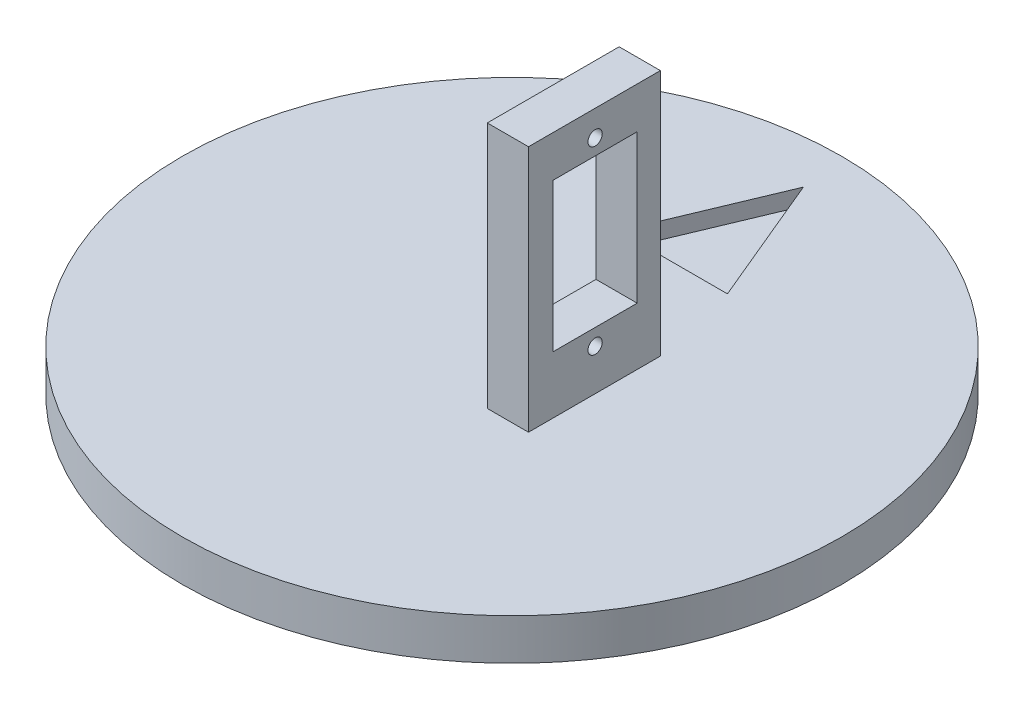
from build123d import *

# Parameters (mm, degrees)
SKETCH1_R           = 50.8
BOSS_EXTRUDE1_DEPTH = 6.35
SKETCH2_W           = 6.35
SKETCH2_H           = 20.32
BOSS_EXTRUDE2_DEPTH = 38.1
SKETCH3_R           = 1.1
SKETCH3_W           = 12.939919869
SKETCH3_H           = 22.881654632
CUT_EXTRUDE1_DEPTH  = 12.7
CUT_EXTRUDE2_DEPTH  = 2.54


with BuildPart() as part:
    # Sketch1 → Boss-Extrude1 (new body)
    with BuildSketch(Plane(origin=(0, 0, 0), x_dir=(1, 0, 0), z_dir=(0, 1, 0))):
        Circle(SKETCH1_R)
    extrude(amount=BOSS_EXTRUDE1_DEPTH)

    # Sketch2 → Boss-Extrude2 (add)
    with BuildSketch(Plane(origin=(0, 6.35, 0), x_dir=(1, 0, 0), z_dir=(0, 1, 0))):
        with Locations((9.525, 0)):
            Rectangle(SKETCH2_W, SKETCH2_H)
    extrude(amount=BOSS_EXTRUDE2_DEPTH)

    # Sketch3 → Cut-Extrude1 (cut)
    with BuildSketch(Plane(origin=(6.35, 55.246794414, 64.642959957), x_dir=(0, 0, 1), z_dir=(-1, 0, 0))):
        with Locations((-64.750269074, -14.746794414)):
            Circle(SKETCH3_R)
        with Locations((-64.750269074, -42.546794414)):
            Circle(SKETCH3_R)
        with Locations((-64.762919892, -28.608275818)):
            Rectangle(SKETCH3_W, SKETCH3_H)
    extrude(amount=-CUT_EXTRUDE1_DEPTH, mode=Mode.SUBTRACT)

    # Sketch4 → Cut-Extrude2 (cut)
    with BuildSketch(Plane(origin=(0, 6.35, 0), x_dir=(1, 0, 0), z_dir=(0, 1, 0))):
        Polygon((-7.230978109, 23.634136505), (9.560420722, 23.634136505), (1.164721306, 43.725579037), align=None)
    extrude(amount=-CUT_EXTRUDE2_DEPTH, mode=Mode.SUBTRACT)


solid = part.part
